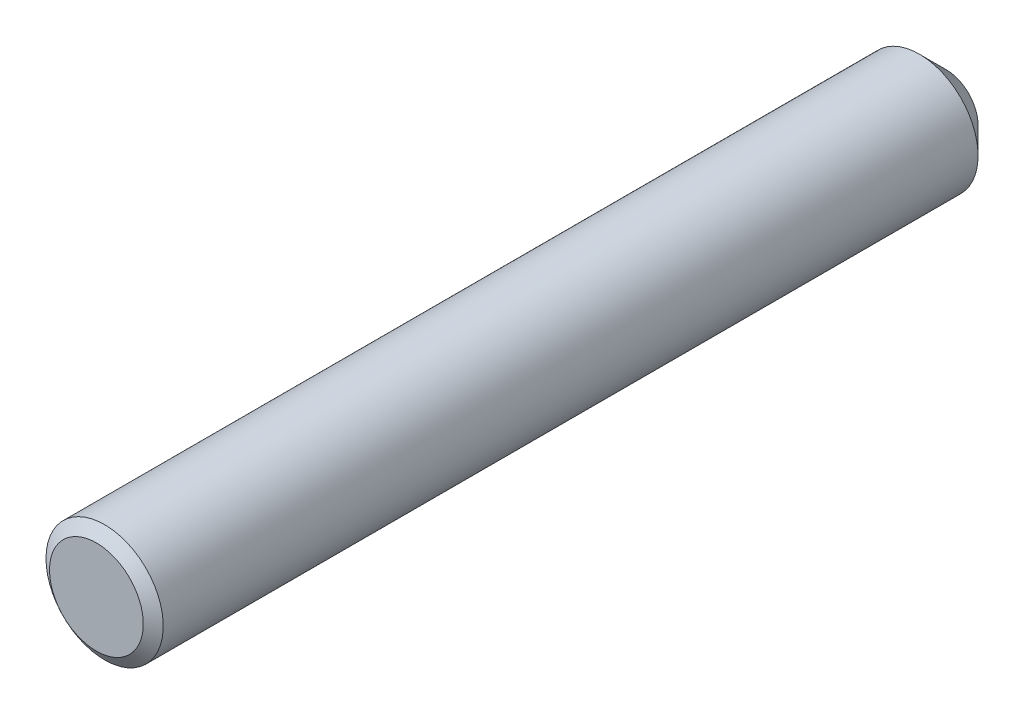
from build123d import *


with BuildPart() as part:
    # Sketch22 → Revolve1 (revolve)
    with BuildSketch(Plane(origin=(0, 0, 0), x_dir=(0, 0, -1), z_dir=(1, 0, 0))):
        Polygon((-12.7, 0), (-12.7, 1.40208), (-12.454563254, 1.7526), (11.90625, 1.7526), (12.7, 0.95885), (12.7, 0), align=None)
    revolve(axis=Axis((0, 0, -12.7), (0, 0, 1)))


solid = part.part
